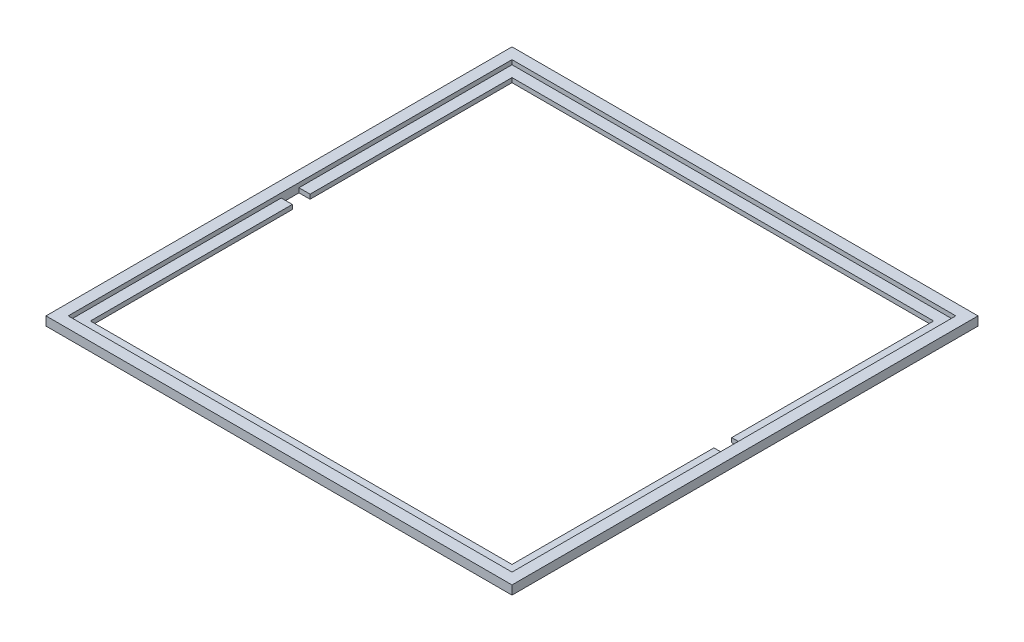
from build123d import *

# Parameters (mm, degrees)
SKETCH1_W           = 210
SKETCH1_H           = 210
BOSS_EXTRUDE1_DEPTH = 2
SKETCH1_4_W         = 210
SKETCH1_4_H         = 210
BOSS_EXTRUDE2_DEPTH = 4


with BuildPart() as part:
    # Sketch1 → Boss-Extrude1 (new body)
    with BuildSketch(Plane(origin=(0, 0, 0), x_dir=(1, 0, 0), z_dir=(0, 1, 0))):
        with Locations((100, 100)):
            Rectangle(SKETCH1_W, SKETCH1_H)
        Polygon((200, 104), (200, 96), (195, 96), (195, 5), (5, 5), (5, 96), (0, 96), (0, 104), (5, 104), (5, 195), (195, 195), (195, 104), align=None, mode=Mode.SUBTRACT)
    extrude(amount=BOSS_EXTRUDE1_DEPTH)

    # Sketch1_4 → Boss-Extrude2 (add)
    with BuildSketch(Plane(origin=(0, 0, 0), x_dir=(1, 0, 0), z_dir=(0, 1, 0))):
        with Locations((100, 100)):
            Rectangle(SKETCH1_4_W, SKETCH1_4_H)
        Polygon((200, 0), (0, 0), (0, 96), (0, 104), (0, 200), (200, 200), (200, 104), (200, 96), align=None, mode=Mode.SUBTRACT)
    extrude(amount=BOSS_EXTRUDE2_DEPTH)


solid = part.part
